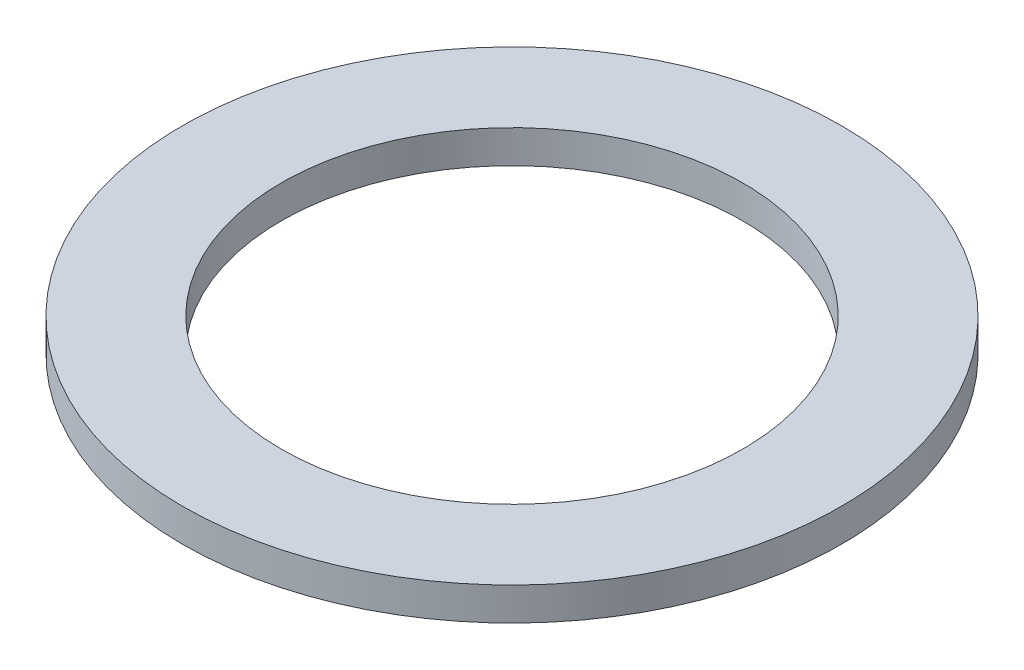
from build123d import *

# Parameters (mm, degrees)
SKETCH1_R           = 10
BOSS_EXTRUDE1_DEPTH = 1
SKETCH5_R           = 7
CUT_EXTRUDE1_DEPTH  = 2


with BuildPart() as part:
    # Sketch1 → Boss-Extrude1 (new body)
    with BuildSketch(Plane(origin=(0, 0, 0), x_dir=(1, 0, 0), z_dir=(0, 1, 0))):
        Circle(SKETCH1_R)
    extrude(amount=BOSS_EXTRUDE1_DEPTH)

    # Sketch5 → Cut-Extrude1 (cut, through all)
    with BuildSketch(Plane(origin=(0, 1, 0), x_dir=(-1, 0, 0), z_dir=(0, 1, 0))):
        Circle(SKETCH5_R)
    extrude(amount=-CUT_EXTRUDE1_DEPTH, mode=Mode.SUBTRACT)


solid = part.part
